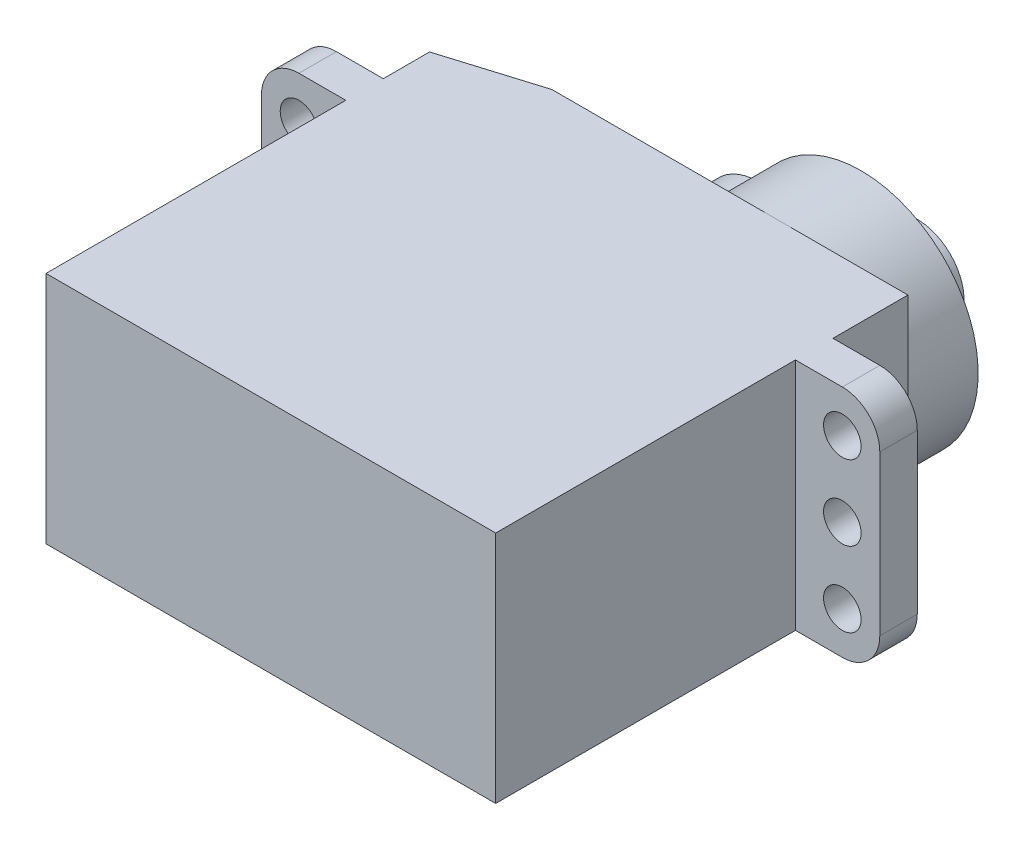
from build123d import *

# Parameters (mm, degrees)
BOSS_EXTRUDE1_DEPTH = 12.5
SKETCH2_R           = 3
SKETCH2_R_2         = 6.25
BOSS_EXTRUDE2_DEPTH = 4.5
SKETCH3_R           = 2.5
SKETCH3_R_2         = 1
BOSS_EXTRUDE3_DEPTH = 3
SKETCH4_R           = 1
CUT_EXTRUDE1_DEPTH  = 2
FILLET1_R           = 2
CHAMFER1_SIZE       = 5
CHAMFER1_SIZE2      = 1.528653407


with BuildPart() as part:
    # Sketch1 → Boss-Extrude1 (new body)
    with BuildSketch(Plane(origin=(0, 0, 0), x_dir=(1, 0, 0), z_dir=(0, 1, 0))):
        Polygon((-12, 0), (-12, 16), (-16.5, 16), (-16.5, 18), (-12, 18), (-12, 22), (12, 22), (12, 18), (16.5, 18), (16.5, 16), (12, 16), (12, 0), align=None)
    extrude(amount=BOSS_EXTRUDE1_DEPTH)

    # Sketch2 → Boss-Extrude2 (add)
    with BuildSketch(Plane(origin=(0, 0, -22), x_dir=(-1, 0, 0), z_dir=(0, 0, -1))):
        with Locations((0.48292805, 6.25)):
            Circle(SKETCH2_R)
        with Locations((-5, 6.25)):
            Circle(SKETCH2_R_2)
    extrude(amount=BOSS_EXTRUDE2_DEPTH)

    # Sketch3 → Boss-Extrude3 (add)
    with BuildSketch(Plane(origin=(0, 0, -26.5), x_dir=(-1, 0, 0), z_dir=(0, 0, -1))):
        with Locations((-5, 6.25)):
            Circle(SKETCH3_R)
        with Locations((-5, 6.25)):
            Circle(SKETCH3_R_2, mode=Mode.SUBTRACT)
    extrude(amount=BOSS_EXTRUDE3_DEPTH)

    # Sketch4 → Cut-Extrude1 (cut)
    with BuildSketch(Plane(origin=(0, 0, -18), x_dir=(-1, 0, 0), z_dir=(0, 0, -1))):
        with Locations((-14.5, 6.25)):
            Circle(SKETCH4_R)
        with Locations((-14.5, 10.25)):
            Circle(SKETCH4_R)
        with Locations((-14.5, 2.25)):
            Circle(SKETCH4_R)
    cut_extrude1 = extrude(amount=-CUT_EXTRUDE1_DEPTH, mode=Mode.SUBTRACT)

    # Mirror1: Cut-Extrude1 across plane
    add(cut_extrude1.mirror(Plane(origin=(0, 0, 0), x_dir=(0, 0, 1), z_dir=(1, 0, 0))), mode=Mode.SUBTRACT)

    # Fillet1
    fillet1_edges = [part.edges().sort_by_distance(p)[0] for p in [
        (-16.5, 0, -17),
        (16.5, 12.5, -17),
        (16.5, 0, -17),
        (-16.5, 12.5, -17),
    ]]
    fillet(fillet1_edges, radius=FILLET1_R)

    # Chamfer1
    chamfer1_edges = [part.edges().sort_by_distance(p)[0] for p in [
        (-12, 6.25, -22),
    ]]
    chamfer1_side = [part.faces().sort_by_distance(p)[0] for p in [
        (-6.176633795, 6.25, -22),
    ]]
    chamfer(chamfer1_edges, length=CHAMFER1_SIZE, length2=CHAMFER1_SIZE2, reference=chamfer1_side[0])


solid = part.part
